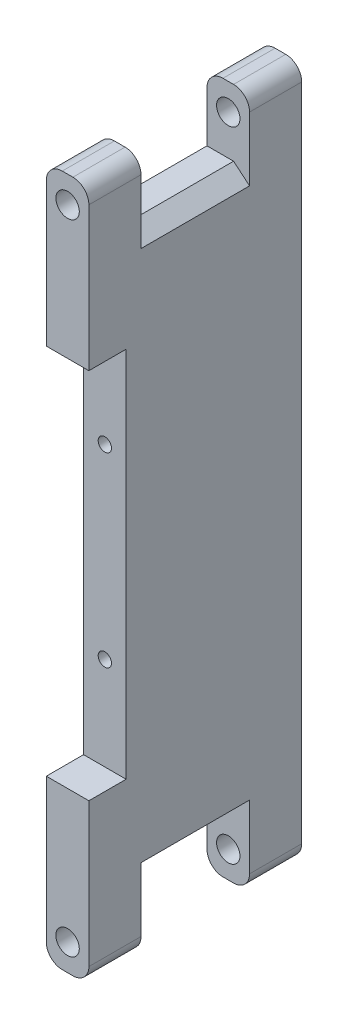
from build123d import *

# Parameters (mm, degrees)
SKETCH1_W             = 8
SKETCH1_H             = 130
BOSS_EXTRUDE1_DEPTH   = 40
SKETCH2_W             = 20.4
SKETCH2_H             = 25
CUT_EXTRUDE1_DEPTH    = 9
FILLET1_R             = 3
SKETCH3_R             = 2.2
CUT_EXTRUDE2_DEPTH    = 41
SKETCH4_W             = 56.10425639
SKETCH4_H             = 70
CUT_EXTRUDE3_DEPTH    = 7
SKETCH5_R             = 1.25
CUT_EXTRUDE4_DEPTH    = 15
CHAMFER1_SIZE         = 3
CHAMFER1_SIZE2        = 2.517298894
CHAMFER1_PART_2_SIZE  = 3
CHAMFER1_PART_2_SIZE2 = 2.517298894


with BuildPart() as part:
    # Sketch1 → Boss-Extrude1 (new body)
    with BuildSketch(Plane.XY):
        Rectangle(SKETCH1_W, SKETCH1_H)
    extrude(amount=-BOSS_EXTRUDE1_DEPTH)

    # Sketch2 → Cut-Extrude1 (cut, through all)
    with BuildSketch(Plane(origin=(4, 0, 0), x_dir=(0, 0, -1), z_dir=(1, 0, 0))):
        with Locations((20, 65)):
            Rectangle(SKETCH2_W, SKETCH2_H)
        with Locations((20, -65)):
            Rectangle(SKETCH2_W, SKETCH2_H)
    extrude(amount=-CUT_EXTRUDE1_DEPTH, mode=Mode.SUBTRACT)

    # Fillet1
    fillet1_edges = [part.edges().sort_by_distance(p)[0] for p in [
        (4, 65, -4.9),
        (-4, 65, -4.9),
        (-4, -65, -4.9),
        (4, -65, -4.9),
        (4, -65, -35.1),
        (-4, -65, -35.1),
        (-4, 65, -35.1),
        (4, 65, -35.1),
    ]]
    fillet(fillet1_edges, radius=FILLET1_R)

    # Sketch3 → Cut-Extrude2 (cut, through all)
    with BuildSketch(Plane.XY):
        with Locations((0, 60)):
            Circle(SKETCH3_R)
        with Locations((0, -60)):
            Circle(SKETCH3_R)
    extrude(amount=-CUT_EXTRUDE2_DEPTH, mode=Mode.SUBTRACT)

    # Sketch4 → Cut-Extrude3 (cut)
    with BuildSketch(Plane.XY):
        Rectangle(SKETCH4_W, SKETCH4_H)
    extrude(amount=-CUT_EXTRUDE3_DEPTH, mode=Mode.SUBTRACT)

    # Sketch5 → Cut-Extrude4 (cut)
    with BuildSketch(Plane.XY.offset(-7)):
        with Locations((0, 17.5)):
            Circle(SKETCH5_R)
        with Locations((0, -17.5)):
            Circle(SKETCH5_R)
    extrude(amount=-CUT_EXTRUDE4_DEPTH, mode=Mode.SUBTRACT)

    # Chamfer1
    chamfer1_edges = [part.edges().sort_by_distance(p)[0] for p in [
        (4, 52.5, -20),
    ]]
    chamfer1_side = [part.faces().sort_by_distance(p)[0] for p in [
        (0, 52.5, -20),
    ]]
    chamfer(chamfer1_edges, length=CHAMFER1_SIZE, length2=CHAMFER1_SIZE2, reference=chamfer1_side[0])

    # Chamfer1 part 2
    chamfer1_part_2_edges = [part.edges().sort_by_distance(p)[0] for p in [
        (4, -52.5, -20),
    ]]
    chamfer1_part_2_side = [part.faces().sort_by_distance(p)[0] for p in [
        (0, -52.5, -20),
    ]]
    chamfer(chamfer1_part_2_edges, length=CHAMFER1_PART_2_SIZE, length2=CHAMFER1_PART_2_SIZE2, reference=chamfer1_part_2_side[0])


solid = part.part
